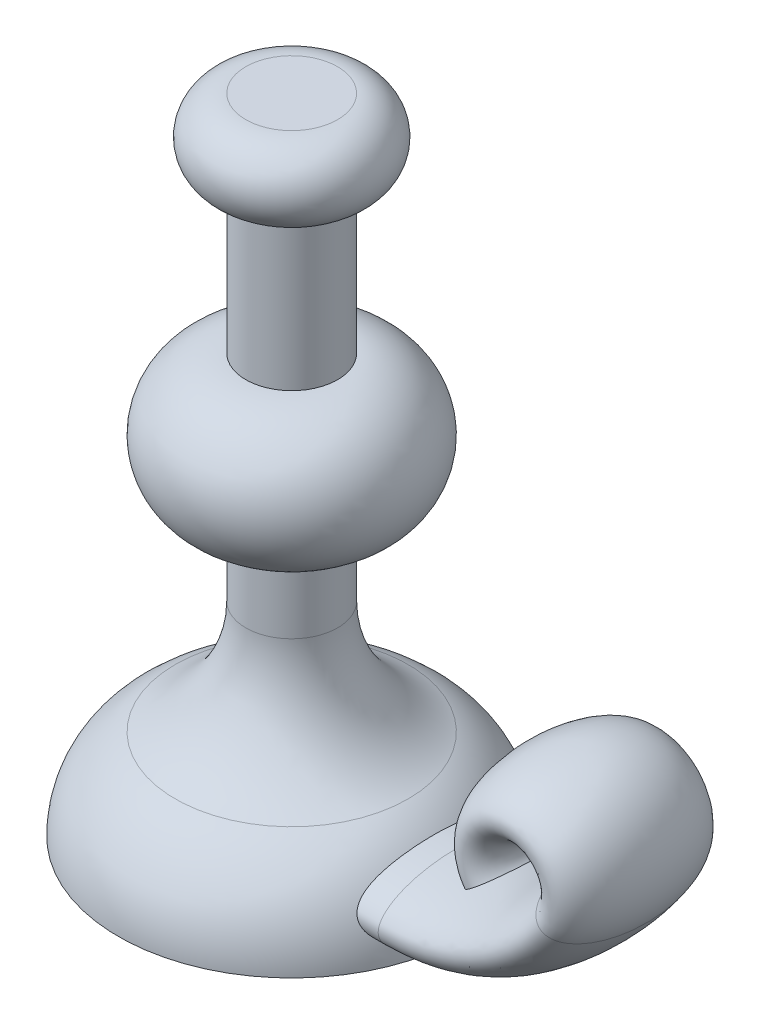
from build123d import *

# Parameters (mm, degrees)
SKETCH4_RX = 27.316283399
SKETCH4_RY = 11.677824467


with BuildPart() as part:
    # Sketch1 → Revolve1 (revolve)
    with BuildSketch(Plane.XY):
        with BuildLine():
            Line((0, 118.049892275), (15.901626361, 118.049892275))
            ThreePointArc((15.901626361, 118.049892275), (28.965195086, 104.98632355), (15.901626361, 91.922754826))
            Line((15.901626361, 91.922754826), (15.901626361, 40.044409962))
            ThreePointArc((15.901626361, 40.044409962), (40.337078652, 15.608957671), (15.901626361, -8.82649462))
            Line((15.901626361, -8.82649462), (15.901626361, -34.389737016))
            ThreePointArc((15.901626361, -34.389737016), (22.5129561, -57.442096603), (40.337078652, -73.486460681))
            ThreePointArc((40.337078652, -73.486460681), (54.67994064, -86.397171939), (60, -104.947134839))
            Line((60, -104.947134839), (0, -104.947134839))
            Line((0, -104.947134839), (0, 118.049892275))
        make_face()
    revolve(axis=Axis((0, 118.049892275, 0), (0, -1, 0)))

    # Sweep2: sweep along a path in Sketch2
    with BuildLine(Plane.XY) as sweep2_path:
        Line((0, -91.420098686), (57.280323619, -91.420098686))
        ThreePointArc((57.280323619, -91.420098686), (88.890250164, -83.770060287), (113.504272175, -62.513050521))
        ThreePointArc((113.504272175, -62.513050521), (101.197261169, -38.576024862), (88.890250164, -62.513050521))
    # Sketch4 → Sweep2 (sweep)
    with BuildSketch(Plane(origin=(0, -91.420098686, 0), x_dir=(0, 0, -1), z_dir=(1, 0, 0))):
        with Locations((0, 0)):
            Ellipse(SKETCH4_RX, SKETCH4_RY)
    sweep(path=sweep2_path.line)


solid = part.part
